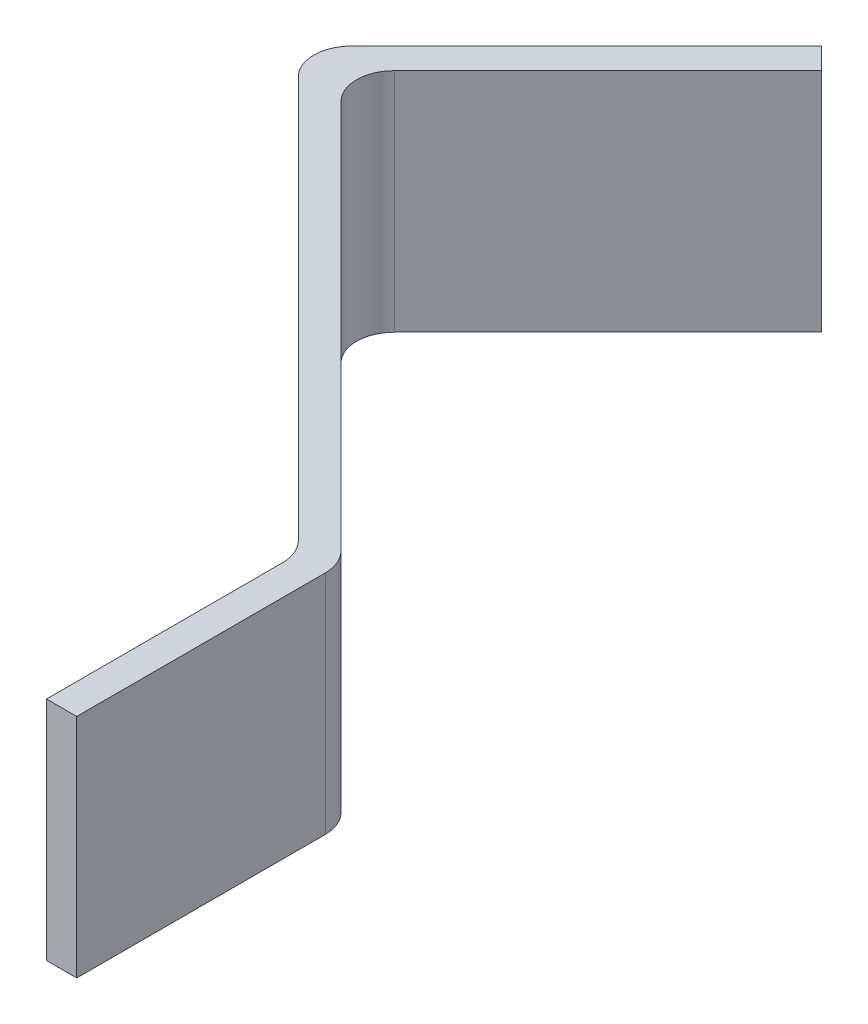
from build123d import *

# Parameters (mm, degrees)
BOSS_EXTRUDE1_DEPTH = 30


with BuildPart() as part:
    # Sketch1 → Boss-Extrude1 (new body)
    with BuildSketch(Plane(origin=(0, 7.5, 0), x_dir=(1, 0, 0), z_dir=(0, 1, 0))):
        with BuildLine():
            Line((-248.792121733, 464.689862838), (-195.566724989, 411.464466094))
            ThreePointArc((-195.566724989, 411.464466094), (-194.482861232, 409.84234935), (-194.102258895, 407.928932188))
            Line((-194.102258895, 407.928932188), (-194.102258895, 376.656854249))
            Line((-194.102258895, 376.656854249), (-190.102258895, 376.656854249))
            Line((-190.102258895, 376.656854249), (-190.102258895, 409.585786438))
            ThreePointArc((-190.102258895, 409.585786438), (-190.482861232, 411.499203599), (-191.566724989, 413.121320344))
            Line((-191.566724989, 413.121320344), (-243.135267484, 464.689862838))
            ThreePointArc((-243.135267484, 464.689862838), (-244.599733578, 468.225396744), (-243.135267484, 471.76093065))
            Line((-243.135267484, 471.76093065), (-214.850996236, 500.045201898))
            Line((-214.850996236, 500.045201898), (-217.679423361, 502.873629023))
            Line((-217.679423361, 502.873629023), (-248.792121733, 471.76093065))
            ThreePointArc((-248.792121733, 471.76093065), (-250.256587827, 468.225396744), (-248.792121733, 464.689862838))
        make_face()
    extrude(amount=-BOSS_EXTRUDE1_DEPTH)


solid = part.part
